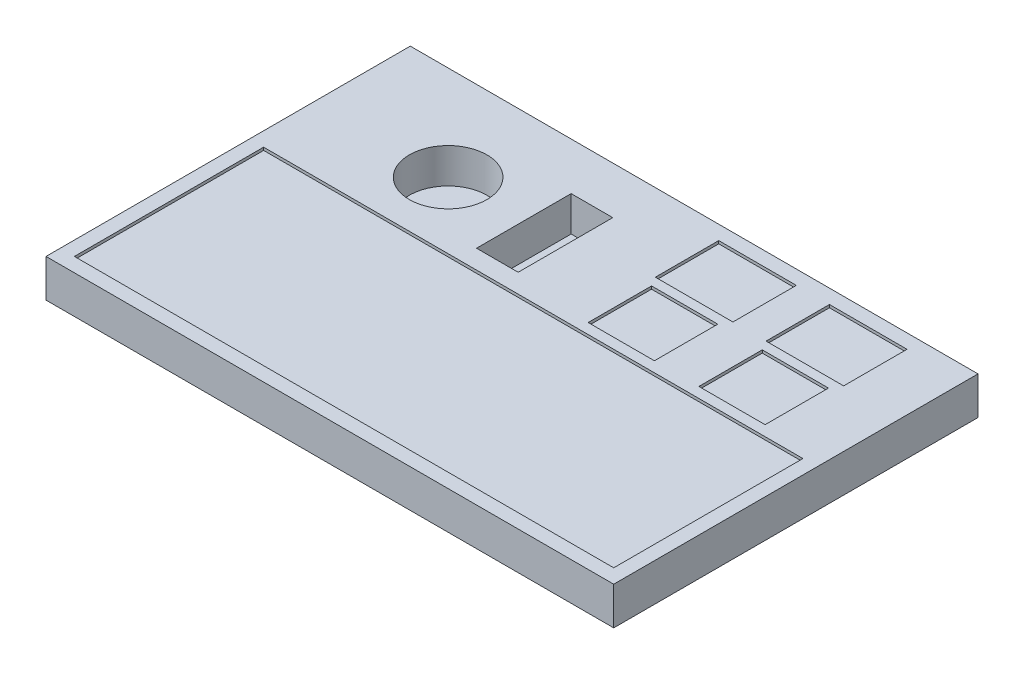
from build123d import *

# Parameters (mm, degrees)
SKETCH1_W           = 600
SKETCH1_H           = 385
BOSS_EXTRUDE1_DEPTH = 40
SKETCH2_W           = 82
SKETCH2_H           = 67
SKETCH2_W_2         = 70
SKETCH2_W_3         = 570
SKETCH2_H_2         = 200
CUT_EXTRUDE1_DEPTH  = 3
SKETCH2_3_R         = 41
SKETCH2_3_W         = 44
SKETCH2_3_H         = 100
CUT_EXTRUDE2_DEPTH  = 37


with BuildPart() as part:
    # Sketch1 → Boss-Extrude1 (new body)
    with BuildSketch(Plane(origin=(0, 0, 0), x_dir=(1, 0, 0), z_dir=(0, 1, 0))):
        Rectangle(SKETCH1_W, SKETCH1_H)
    extrude(amount=-BOSS_EXTRUDE1_DEPTH)

    # Sketch2 → Cut-Extrude1 (cut)
    with BuildSketch(Plane(origin=(0, 0, 0), x_dir=(1, 0, 0), z_dir=(0, 1, 0))):
        with Locations((82, 144)):
            Rectangle(SKETCH2_W, SKETCH2_H)
        with Locations((199, 144)):
            Rectangle(SKETCH2_W, SKETCH2_H)
        with Locations((199, 67)):
            Rectangle(SKETCH2_W_2, SKETCH2_H)
        with Locations((0, -77.5)):
            Rectangle(SKETCH2_W_3, SKETCH2_H_2)
        with Locations((82, 67)):
            Rectangle(SKETCH2_W_2, SKETCH2_H)
    extrude(amount=-CUT_EXTRUDE1_DEPTH, mode=Mode.SUBTRACT)

    # Sketch2_3 → Cut-Extrude2 (cut)
    with BuildSketch(Plane(origin=(0, 0, 0), x_dir=(1, 0, 0), z_dir=(0, 1, 0))):
        with Locations((-160, 92.5)):
            Circle(SKETCH2_3_R)
        with Locations((-58, 92.5)):
            Rectangle(SKETCH2_3_W, SKETCH2_3_H)
    extrude(amount=-CUT_EXTRUDE2_DEPTH, mode=Mode.SUBTRACT)


solid = part.part
